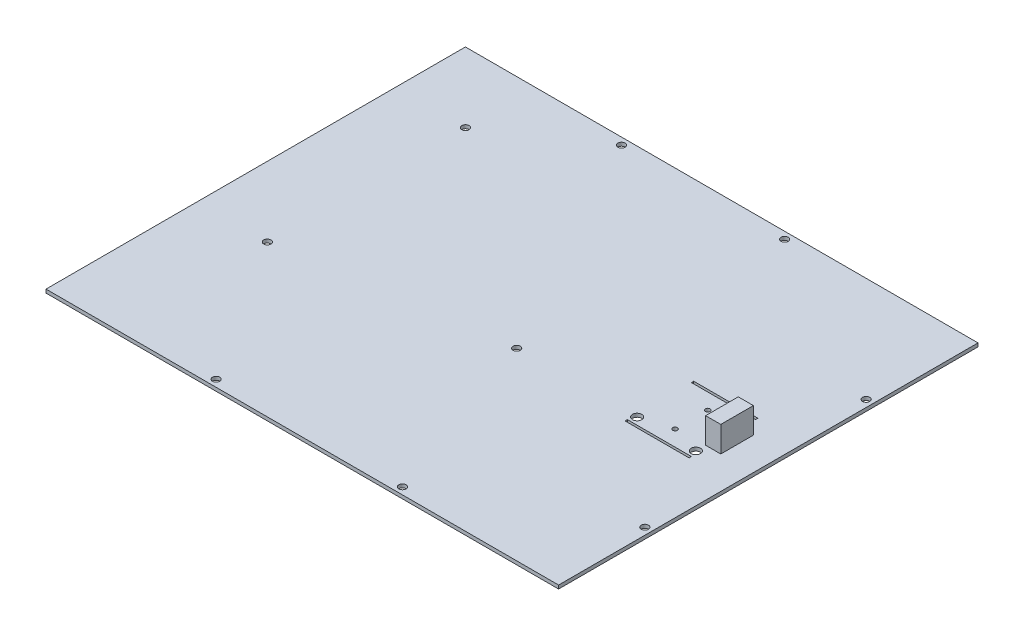
from build123d import *

# Parameters (mm, degrees)
SKETCH1_W           = 220
SKETCH1_H           = 180
SKETCH1_R           = 1.55
BOSS_EXTRUDE1_DEPTH = 1.5
SKETCH_1_R          = 1
SKETCH_1_R_2        = 2
SKETCH_1_W          = 27.5
SKETCH_1_H          = 1
CUT_EXTRUDE_1_DEPTH = 2.5
SKETCH3_W           = 6.5
SKETCH3_H           = 14
BOSS_EXTRUDE2_DEPTH = 11


with BuildPart() as part:
    # Sketch1 → Boss-Extrude1 (new body)
    with BuildSketch(Plane(origin=(0, 0, 0), x_dir=(1, 0, 0), z_dir=(0, 1, 0))):
        with Locations((110, 90)):
            Rectangle(SKETCH1_W, SKETCH1_H)
        with Locations((70, 177)):
            Circle(SKETCH1_R, mode=Mode.SUBTRACT)
        with Locations((140, 177)):
            Circle(SKETCH1_R, mode=Mode.SUBTRACT)
        with Locations((30, 150)):
            Circle(SKETCH1_R, mode=Mode.SUBTRACT)
        with Locations((30, 65)):
            Circle(SKETCH1_R, mode=Mode.SUBTRACT)
        with Locations((217, 40)):
            Circle(SKETCH1_R, mode=Mode.SUBTRACT)
        with Locations((217, 135)):
            Circle(SKETCH1_R, mode=Mode.SUBTRACT)
        with Locations((70, 3)):
            Circle(SKETCH1_R, mode=Mode.SUBTRACT)
        with Locations((150, 3)):
            Circle(SKETCH1_R, mode=Mode.SUBTRACT)
        with Locations((123, 79)):
            Circle(SKETCH1_R, mode=Mode.SUBTRACT)
    extrude(amount=BOSS_EXTRUDE1_DEPTH)

    # Эскиз1 → Вырез-Вытянуть1 (cut, through all)
    with BuildSketch(Plane(origin=(0, 1.5, 0), x_dir=(1, 0, 0), z_dir=(0, 1, 0))):
        with Locations((187, 83)):
            Circle(SKETCH_1_R)
        with Locations((187, 97)):
            Circle(SKETCH_1_R)
        with Locations((199.6, 79.3)):
            Circle(SKETCH_1_R_2)
        with Locations((199.6, 100.7)):
            Circle(SKETCH_1_R_2)
        with Locations((174.4, 79.3)):
            Circle(SKETCH_1_R_2)
        with Locations((187, 75.75)):
            Rectangle(SKETCH_1_W, SKETCH_1_H)
        with Locations((187, 104.25)):
            Rectangle(SKETCH_1_W, SKETCH_1_H)
    extrude(amount=-CUT_EXTRUDE_1_DEPTH, mode=Mode.SUBTRACT)

    # Sketch3 → Boss-Extrude2 (add)
    with BuildSketch(Plane(origin=(0, 1.5, 0), x_dir=(1, 0, 0), z_dir=(0, 1, 0))):
        with Locations((202.85, 90.5)):
            Rectangle(SKETCH3_W, SKETCH3_H)
    extrude(amount=BOSS_EXTRUDE2_DEPTH)


solid = part.part
